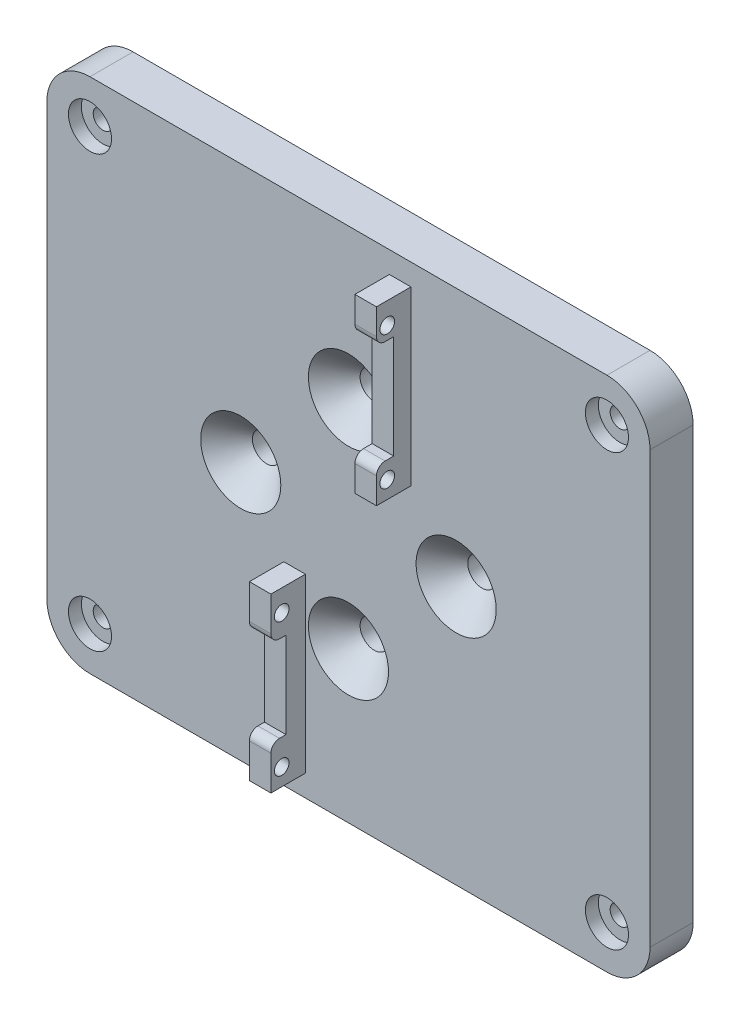
from build123d import *

# Parameters (mm, degrees)
SKETCH_1_W                   = 140
SKETCH_1_H                   = 120
EXTRUDE_1_DEPTH              = 10
HOLE_WIZARD_M6_1_D           = 6.6
HOLE_WIZARD_M6_1_CSINK_D     = 18.6
HOLE_WIZARD_M6_1_CSINK_ANGLE = 90
SKETCH_4_W                   = 5
SKETCH_4_H                   = 40
EXTRUDE_2_DEPTH              = 8
HOLE_WIZARD_M3_2_D           = 3.4
HOLE_WIZARD_M3_2_DEPTH       = 5
SKETCH_13_R                  = 5
CUT_EXTRUDE_5_DEPTH          = 3
HOLE_WIZARD_M4_1_D           = 4.5
HOLE_WIZARD_M4_1_CBORE_D     = 9
HOLE_WIZARD_M4_1_CBORE_DEPTH = 3.1
SKETCH_21_W                  = 5
SKETCH_21_H                  = 40
EXTRUDE_4_DEPTH              = 8
HOLE_WIZARD_M3_4_D           = 3.4
SKETCH_24_W                  = 3.5
SKETCH_24_H                  = 20
SKETCH_24_W_2                = 4
SKETCH_24_H_2                = 24
CUT_EXTRUDE_6_DEPTH          = 81
CUT_EXTRUDE_6_DEPTH_BACK     = 61
FILLET_1_R                   = 10
FILLET_2_R                   = 2


with BuildPart() as part:
    # 스케치1 → 보스-돌출1 (new body)
    with BuildSketch(Plane.XY):
        Rectangle(SKETCH_1_W, SKETCH_1_H)
    extrude(amount=EXTRUDE_1_DEPTH)

    # M6 접시 머리 나사용 카운터싱크1 (through all)
    with Locations(Plane.XY.offset(10)):
        with Locations((0, 25), (25, 0), (0, -25), (-25, 0)):
            CounterSinkHole(HOLE_WIZARD_M6_1_D / 2, HOLE_WIZARD_M6_1_CSINK_D / 2, counter_sink_angle=HOLE_WIZARD_M6_1_CSINK_ANGLE)

    # 스케치4 → 보스-돌출2 (add)
    with BuildSketch(Plane.XY.offset(10)):
        with Locations((-12.5, -35)):
            Rectangle(SKETCH_4_W, SKETCH_4_H)
    extrude(amount=EXTRUDE_2_DEPTH)

    # M3 여유 구멍2
    with Locations(Plane(origin=(-10, 0, 0), x_dir=(0, 0, -1), z_dir=(1, 0, 0))):
        with Locations((-15.5, -51), (-15.5, -20)):
            Hole(HOLE_WIZARD_M3_2_D / 2, depth=HOLE_WIZARD_M3_2_DEPTH)

    # 스케치13 → 컷-돌출5 (cut)
    with BuildSketch(Plane.XY.offset(10)):
        with Locations((-60, 50)):
            Circle(SKETCH_13_R)
        with Locations((60, 50)):
            Circle(SKETCH_13_R)
        with Locations((60, -50)):
            Circle(SKETCH_13_R)
        with Locations((-60, -50)):
            Circle(SKETCH_13_R)
    extrude(amount=-CUT_EXTRUDE_5_DEPTH, mode=Mode.SUBTRACT)

    # M4 남비 머리 나사용 카운터보어1 (through all)
    with Locations(Plane(origin=(0, 0, 0), x_dir=(-1, 0, 0), z_dir=(0, 0, -1))):
        with Locations((-60, 50), (60, 50), (60, -50), (-60, -50)):
            CounterBoreHole(HOLE_WIZARD_M4_1_D / 2, HOLE_WIZARD_M4_1_CBORE_D / 2, HOLE_WIZARD_M4_1_CBORE_DEPTH)

    # 스케치21 → 보스-돌출4 (add)
    with BuildSketch(Plane.XY.offset(10)):
        with Locations((12, 35)):
            Rectangle(SKETCH_21_W, SKETCH_21_H)
    extrude(amount=EXTRUDE_4_DEPTH)

    # M3 여유 구멍4 (through all)
    with Locations(Plane.ZY.offset(-9.5)):
        with Locations((15.5, 50), (15.5, 19)):
            Hole(HOLE_WIZARD_M3_4_D / 2)

    # 스케치24 → 컷-돌출6 (cut, two sides)
    with BuildSketch(Plane(origin=(-10, 0, 0), x_dir=(0, 0, -1), z_dir=(1, 0, 0))) as cut_extrude_6_sk:
        with Locations((-16.25, -35)):
            Rectangle(SKETCH_24_W, SKETCH_24_H)
        with Locations((-16, 35)):
            Rectangle(SKETCH_24_W_2, SKETCH_24_H_2)
    extrude(amount=CUT_EXTRUDE_6_DEPTH, mode=Mode.SUBTRACT)
    extrude(cut_extrude_6_sk.sketch, amount=-CUT_EXTRUDE_6_DEPTH_BACK, mode=Mode.SUBTRACT)

    # 필렛1
    fillet_1_edges = [part.edges().sort_by_distance(p)[0] for p in [
        (70, -60, 5),
        (-70, -60, 5),
        (-70, 60, 5),
        (70, 60, 5),
    ]]
    fillet(fillet_1_edges, radius=FILLET_1_R)

    # 필렛2
    fillet_2_edges = [part.edges().sort_by_distance(p)[0] for p in [
        (12, 47, 18),
        (12, 23, 18),
        (-12.5, -25, 18),
        (-12.5, -45, 18),
    ]]
    fillet(fillet_2_edges, radius=FILLET_2_R)


solid = part.part
